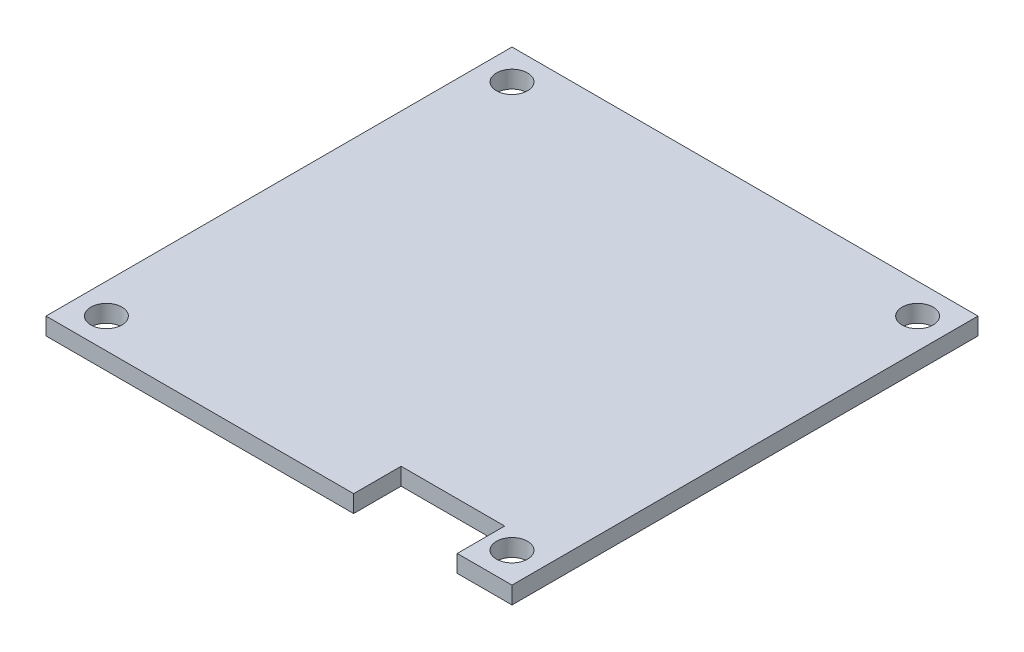
from build123d import *

# Parameters (mm, degrees)
SKETCH_3_R      = 1.8
EXTRUDE_2_DEPTH = 2


with BuildPart() as part:
    # 草图3 → 凸台-拉伸2 (new body)
    with BuildSketch(Plane(origin=(0, 0, 0), x_dir=(1, 0, 0), z_dir=(0, 1, 0))):
        Polygon((27, 27), (-27, 27), (-27, -27), (8.65, -27), (8.65, -21.5), (20.65, -21.5), (20.65, -27), (27, -27), align=None)
        with Locations((-23.5, -23.5)):
            Circle(SKETCH_3_R, mode=Mode.SUBTRACT)
        with Locations((23.5, -23.5)):
            Circle(SKETCH_3_R, mode=Mode.SUBTRACT)
        with Locations((-23.5, 23.5)):
            Circle(SKETCH_3_R, mode=Mode.SUBTRACT)
        with Locations((23.5, 23.5)):
            Circle(SKETCH_3_R, mode=Mode.SUBTRACT)
    extrude(amount=EXTRUDE_2_DEPTH)


solid = part.part
